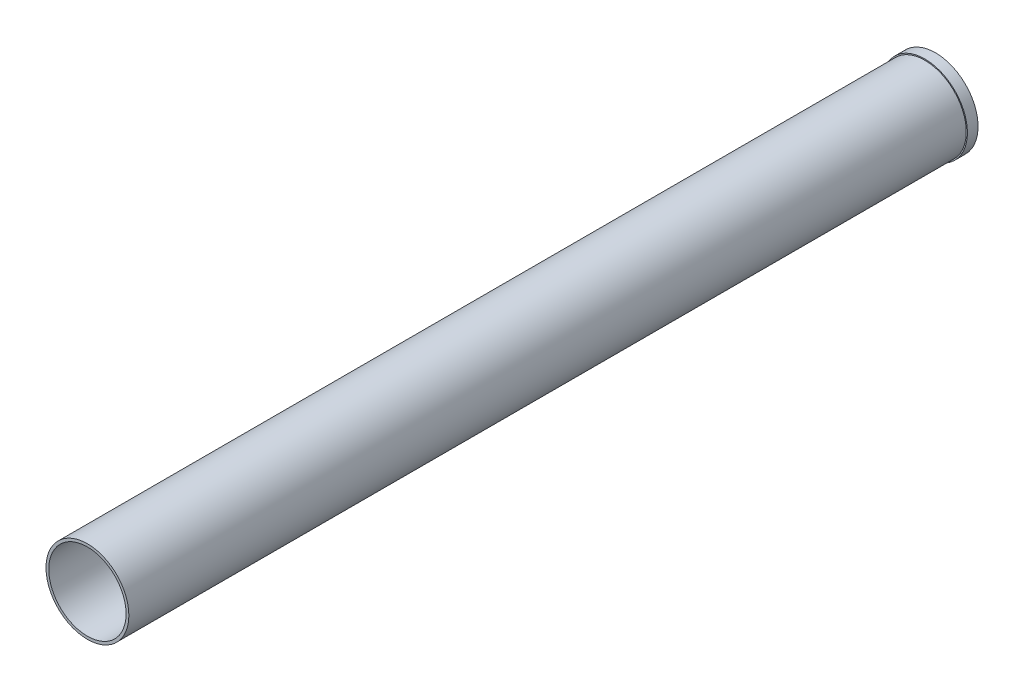
from build123d import *

# Parameters (mm, degrees)
SKETCH1_R           = 49.3141
SKETCH1_R_2         = 46.0502
BOSS_EXTRUDE1_DEPTH = 1009.65
SKETCH2_R           = 50.673
SKETCH2_R_2         = 49.3141
BOSS_EXTRUDE2_DEPTH = 12.7


with BuildPart() as part:
    # Sketch1 → Boss-Extrude1 (new body)
    with BuildSketch(Plane.XY):
        Circle(SKETCH1_R)
        Circle(SKETCH1_R_2, mode=Mode.SUBTRACT)
    extrude(amount=BOSS_EXTRUDE1_DEPTH)

    # Sketch2 → Boss-Extrude2 (add)
    with BuildSketch(Plane(origin=(0, 0, 0), x_dir=(-1, 0, 0), z_dir=(0, 0, -1))):
        Circle(SKETCH2_R)
        Circle(SKETCH2_R_2, mode=Mode.SUBTRACT)
    extrude(amount=-BOSS_EXTRUDE2_DEPTH)


solid = part.part
